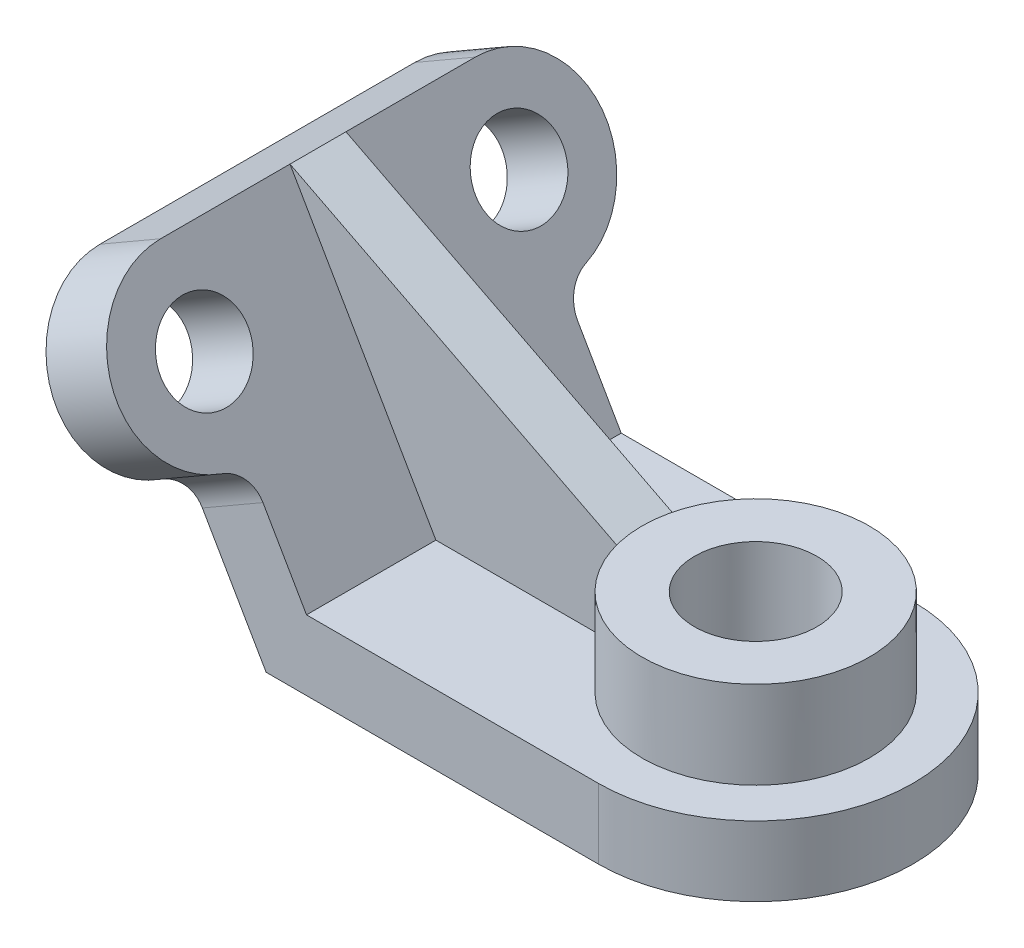
from build123d import *

# Parameters (mm, degrees)
BOSS_EXTRUDE1_DEPTH = 45
BOSS_EXTRUDE2_DEPTH = 20
SKETCH3_R           = 12.5
CUT_EXTRUDE1_DEPTH  = 20
BOSS_EXTRUDE3_DEPTH = 20
SKETCH5_R           = 32.5
SKETCH5_R_2         = 17.5
BOSS_EXTRUDE4_DEPTH = 25
FILLET1_R           = 10
SKETCH8_R           = 17.5
CUT_EXTRUDE2_DEPTH  = 182.698096488
RIB2_REACH          = 183.698
SKETCH9_WALL_W      = 469.435460986
SKETCH9_WALL_H      = 16


with BuildPart() as part:
    # Sketch1 → Boss-Extrude1 (new, symmetric)
    with BuildSketch(Plane.XY):
        Polygon((0, 0), (95, 0), (95, 20), (11.547005384, 20), (-30.179491924, 92.27241336), (-47.5, 82.27241336), align=None)
    extrude(amount=BOSS_EXTRUDE1_DEPTH, both=True)

    # Sketch2 → Boss-Extrude2 (add)
    with BuildSketch(Plane(origin=(17.320508076, 10, 0), x_dir=(0, 0, -1), z_dir=(0.8660254037844396, 0.4999999999999982, 0))):
        with BuildLine():
            Line((-45, 70), (-45, 95))
            ThreePointArc((-45, 95), (-70, 70), (-45, 45))
            Line((-45, 45), (-45, 70))
        make_face()
        with BuildLine():
            ThreePointArc((45, 45), (70, 70), (45, 95))
            Line((45, 95), (45, 45))
        make_face()
    extrude(amount=-BOSS_EXTRUDE2_DEPTH)

    # Sketch3 → Cut-Extrude1 (cut)
    with BuildSketch(Plane(origin=(17.320508076, 10, 0), x_dir=(0, 0, -1), z_dir=(0.8660254037844396, 0.4999999999999982, 0))):
        with Locations(Location((-45, 70, 0), (0, 0, 90))):
            Circle(SKETCH3_R)
        with Locations(Location((45, 70, 0), (0, 0, 90))):
            Circle(SKETCH3_R)
    extrude(amount=-CUT_EXTRUDE1_DEPTH, mode=Mode.SUBTRACT)

    # Sketch4 → Boss-Extrude3 (add)
    with BuildSketch(Plane(origin=(0, 20, 0), x_dir=(1, 0, 0), z_dir=(0, 1, 0))):
        with BuildLine():
            Line((95, 45), (95, -45))
            ThreePointArc((95, -45), (140, 0), (95, 45))
        make_face()
    extrude(amount=-BOSS_EXTRUDE3_DEPTH)

    # Sketch5 → Boss-Extrude4 (add)
    with BuildSketch(Plane(origin=(0, 20, 0), x_dir=(1, 0, 0), z_dir=(0, 1, 0))):
        with Locations(Location((95, 0, 0), (0, 0, 180))):
            Circle(SKETCH5_R)
        with Locations(Location((95, 0, 0), (0, 0, 180))):
            Circle(SKETCH5_R_2, mode=Mode.SUBTRACT)
    extrude(amount=BOSS_EXTRUDE4_DEPTH)

    # Fillet1
    fillet1_edges = [part.edges().sort_by_distance(p)[0] for p in [
        (-13.839745962, 43.97114317, 45),
        (-13.839745962, 43.97114317, -45),
    ]]
    fillet(fillet1_edges, radius=FILLET1_R)

    # Sketch8 → Cut-Extrude2 (cut, through all)
    with BuildSketch(Plane(origin=(0, 0, 0), x_dir=(-1, 0, 0), z_dir=(0, -1, 0))):
        with Locations(Location((-95, 0, 0), (0, 0, 90))):
            Circle(SKETCH8_R)
    extrude(amount=-CUT_EXTRUDE2_DEPTH, mode=Mode.SUBTRACT)

    # Sketch9 wall → Rib2 (add, up to next)
    with BuildSketch(Plane(origin=(16.160254038, 68.63620668, 0), x_dir=(0.890812610433, -0.45437087615, 0), z_dir=(0.45437087615, 0.890812610433, 0)), mode=Mode.PRIVATE) as rib2_sk1:
        Rectangle(SKETCH9_WALL_W, SKETCH9_WALL_H)
    rib2_tool1 = extrude(rib2_sk1.sketch, amount=-RIB2_REACH, mode=Mode.PRIVATE) - part.part
    add(rib2_tool1.solids().sort_by_distance((16.160254038, 68.63620668, 0))[0])


solid = part.part
